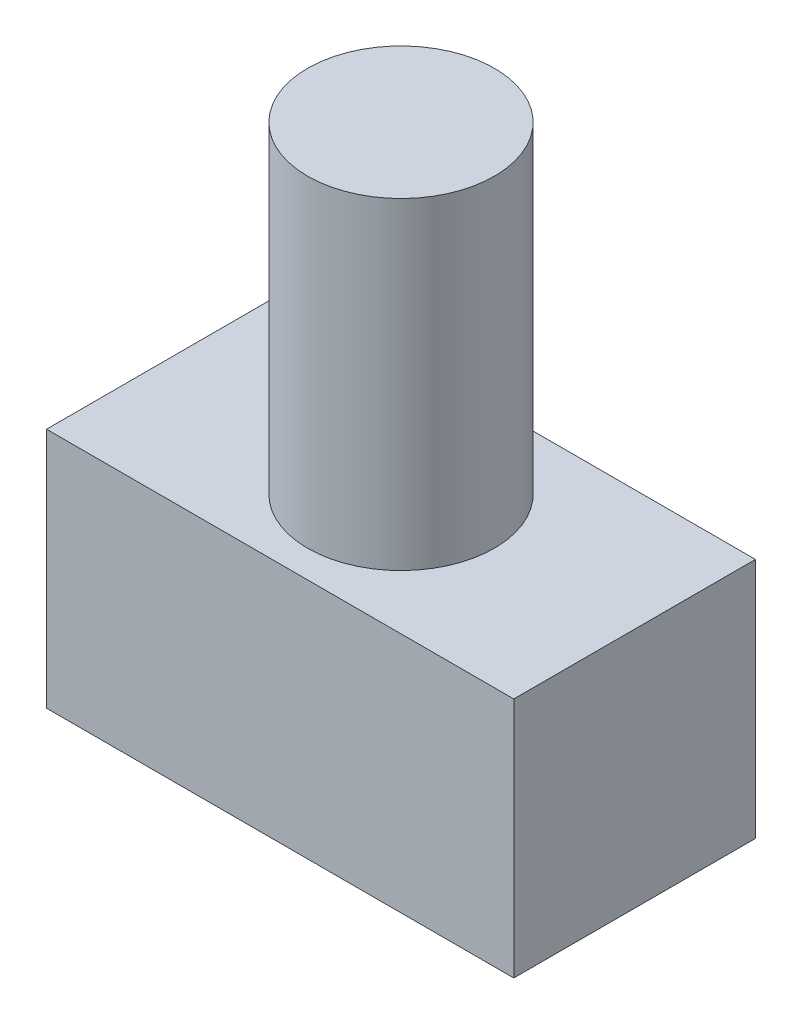
from build123d import *

# Parameters (mm, degrees)
SKETCH1_W           = 29
SKETCH1_H           = 15
BOSS_EXTRUDE1_DEPTH = 15
SKETCH2_R           = 5.8
BOSS_EXTRUDE2_DEPTH = 20
SKETCH3_R           = 2.5
CUT_EXTRUDE1_DEPTH  = 8


with BuildPart() as part:
    # Sketch1 → Boss-Extrude1 (new body)
    with BuildSketch(Plane.XY):
        Rectangle(SKETCH1_W, SKETCH1_H)
    extrude(amount=BOSS_EXTRUDE1_DEPTH)

    # Sketch2 → Boss-Extrude2 (add)
    with BuildSketch(Plane(origin=(0, 7.5, 0), x_dir=(1, 0, 0), z_dir=(0, 1, 0))):
        with Locations((0, -7.5)):
            Circle(SKETCH2_R)
    extrude(amount=BOSS_EXTRUDE2_DEPTH)

    # Sketch3 → Cut-Extrude1 (cut)
    with BuildSketch(Plane(origin=(0, 0, 0), x_dir=(-1, 0, 0), z_dir=(0, 0, -1))):
        Circle(SKETCH3_R)
    extrude(amount=-CUT_EXTRUDE1_DEPTH, mode=Mode.SUBTRACT)


solid = part.part
